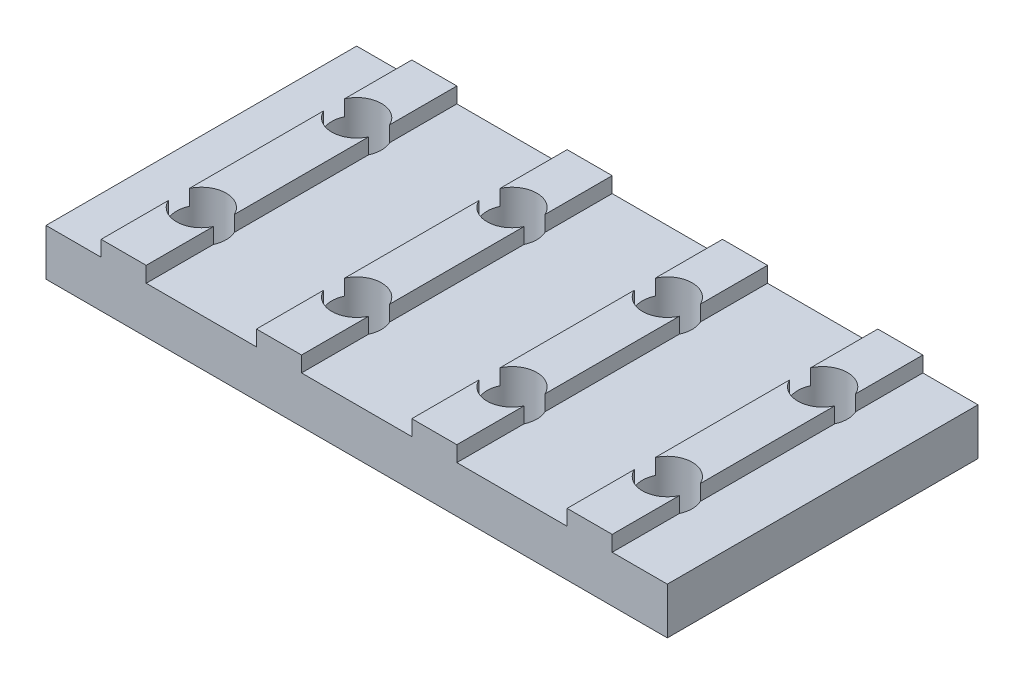
from build123d import *

# Parameters (mm, degrees)
MAIN_DEPTH                 = 20
ESQUISSE2_R                = 1.6
TOPHOLE_DEPTH              = 22
R_P_TITION_LIN_AIRE1_COUNT = 4
R_P_TITION_LIN_AIRE1_PITCH = 10


with BuildPart() as part:
    # Esquisse1 → Main (new body)
    with BuildSketch(Plane.XY):
        Polygon((-5, 0), (-5, 3), (-1.45, 3), (-1.45, 4), (1.45, 4), (1.45, 3), (5, 3), (5, 0), align=None)
    main = extrude(amount=MAIN_DEPTH)

    # Esquisse2 → TopHole (cut, through all)
    with BuildSketch(Plane(origin=(0, 4, 0), x_dir=(1, 0, 0), z_dir=(0, 1, 0))):
        with Locations((0, -5)):
            Circle(ESQUISSE2_R)
        with Locations((0, -15)):
            Circle(ESQUISSE2_R)
    tophole = extrude(amount=-TOPHOLE_DEPTH, mode=Mode.SUBTRACT)

    # Répétition linéaire1: Main, TopHole ×4
    with Locations(*[(-i * R_P_TITION_LIN_AIRE1_PITCH, 0, 0) for i in range(1, R_P_TITION_LIN_AIRE1_COUNT)]):
        add(main)
        add(tophole, mode=Mode.SUBTRACT)


solid = part.part
